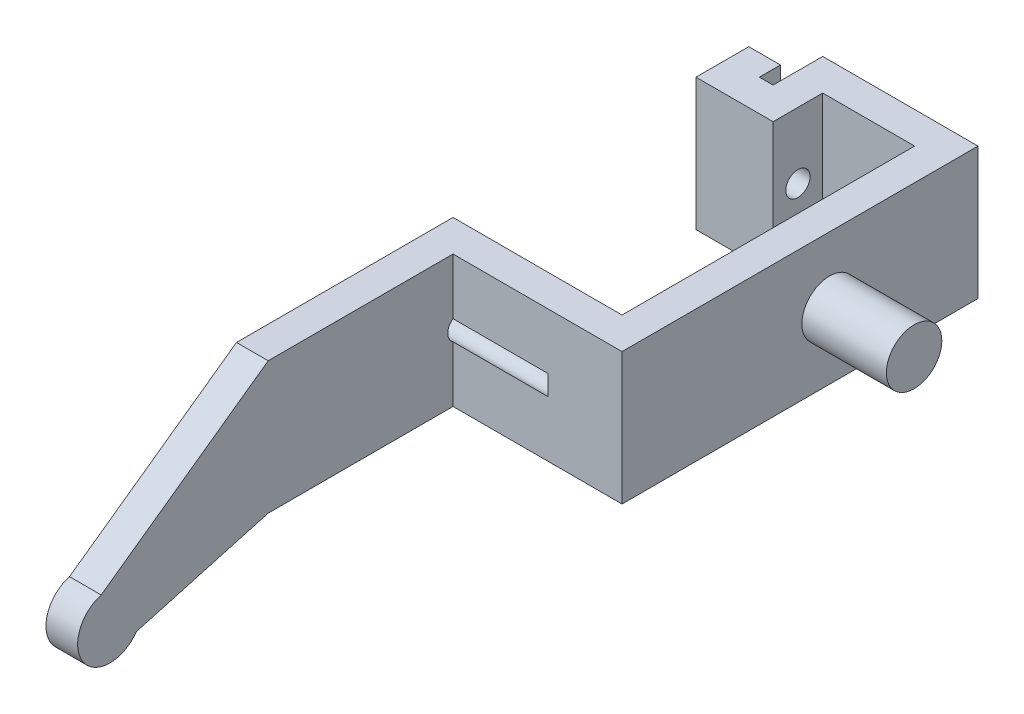
from build123d import *

# Parameters (mm, degrees)
EXTRUDE_1_DEPTH     = 12.5
SKETCH_2_R          = 1.15
CUT_EXTRUDE_1_DEPTH = 12
SKETCH_3_R          = 2.625
EXTRUDE_2_DEPTH     = 8
CUT_EXTRUDE_2_DEPTH = 8
EXTRUDE_3_DEPTH     = 3


with BuildPart() as part:
    # 草图1 → 凸台-拉伸1 (new body)
    with BuildSketch(Plane(origin=(0, 0, 0), x_dir=(1, 0, 0), z_dir=(0, 1, 0))):
        Polygon((0, 5), (0, 0), (7.3, 0), (7.3, 3), (7.3, 4.7), (16, 4.7), (16, 3), (16, 0), (16, -23), (0, -23), (0, -61), (3, -61), (3, -26), (19, -26), (19, 3), (19, 7.7), (4.3, 7.7), (4.3, 3), (3, 3), (3, 5), align=None)
    extrude(amount=EXTRUDE_1_DEPTH)

    # 草图2 → 切除-拉伸1 (cut)
    with BuildSketch(Plane.ZY):
        with Locations((25.35, 6.25)):
            Circle(SKETCH_2_R)
        with Locations((-2.35, 6.25)):
            Circle(SKETCH_2_R)
    extrude(amount=-CUT_EXTRUDE_1_DEPTH, mode=Mode.SUBTRACT)

    # 草图3 → 凸台-拉伸2 (add)
    with BuildSketch(Plane(origin=(19, 0, 0), x_dir=(0, 0, -1), z_dir=(1, 0, 0))):
        with Locations((-6.35, 6.25)):
            Circle(SKETCH_3_R)
    extrude(amount=EXTRUDE_2_DEPTH)

    # 草图4 → 切除-拉伸2 (cut)
    with BuildSketch(Plane(origin=(3, 0, 0), x_dir=(0, 0, -1), z_dir=(1, 0, 0))):
        with BuildLine():
            Line((-61, 12.5), (-61, 0))
            ThreePointArc((-61, 0), (-60.261770725, 0.750275482), (-59.312624964, 1.205267883))
            Line((-59.312624964, 1.205267883), (-43.5, 12.5))
            Line((-43.5, 12.5), (-61, 12.5))
        make_face()
    extrude(amount=-CUT_EXTRUDE_2_DEPTH, mode=Mode.SUBTRACT)

    # 草图4<4> → 凸台-拉伸3 (add)
    with BuildSketch(Plane(origin=(3, 0, 0), x_dir=(0, 0, -1), z_dir=(1, 0, 0))):
        with BuildLine():
            ThreePointArc((-61, 0), (-60.221329006, -4.246956372), (-55.974372634, -3.468285379))
            Line((-55.974372634, -3.468285379), (-43.5, 0))
            Line((-43.5, 0), (-61, 0))
        make_face()
    extrude(amount=-EXTRUDE_3_DEPTH)


solid = part.part
